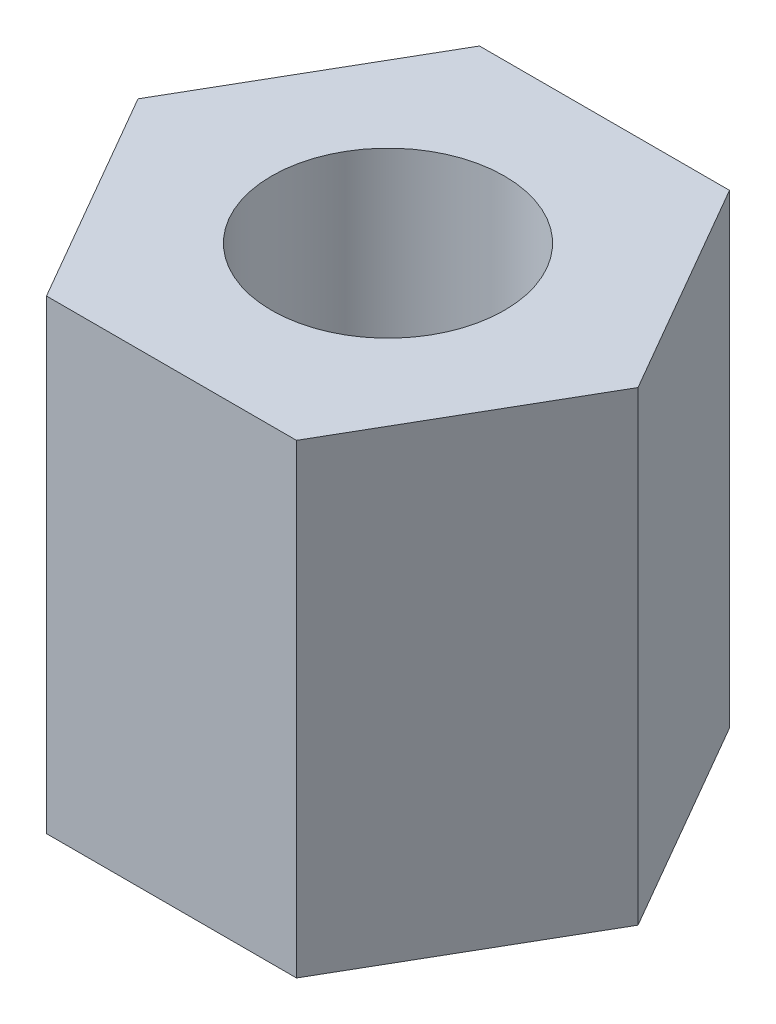
from build123d import *

# Parameters (mm, degrees)
EXTRUDE_1_DEPTH = 2.5


with BuildPart() as part:
    # 草图1 → 凸台-拉伸1 (new body, symmetric)
    with BuildSketch(Plane(origin=(0, 0, 0), x_dir=(1, 0, 0), z_dir=(0, 1, 0))):
        Polygon((2.684678752, 0), (1.342339376, 2.325), (-1.342339376, 2.325), (-2.684678752, 0), (-1.342339376, -2.325), (1.342339376, -2.325), align=None)
    extrude(amount=EXTRUDE_1_DEPTH, both=True)

    # 草图2 → M3 螺纹孔1 (revolve, cut)
    with BuildSketch(Plane(origin=(0, -2.5, 0), x_dir=(0, 0, -1), z_dir=(1, 0, 0))):
        Polygon((0, 0), (0, 8.251075774), (1.25, 7.5), (1.25, 0), align=None)
    hole_wizard_m3_1 = revolve(axis=Axis((0, -8.85, 0), (0, 1, 0)), mode=Mode.SUBTRACT)

    # 镜向1: M3 螺纹孔1 across plane
    add(hole_wizard_m3_1.mirror(Plane.ZX), mode=Mode.SUBTRACT)


solid = part.part
